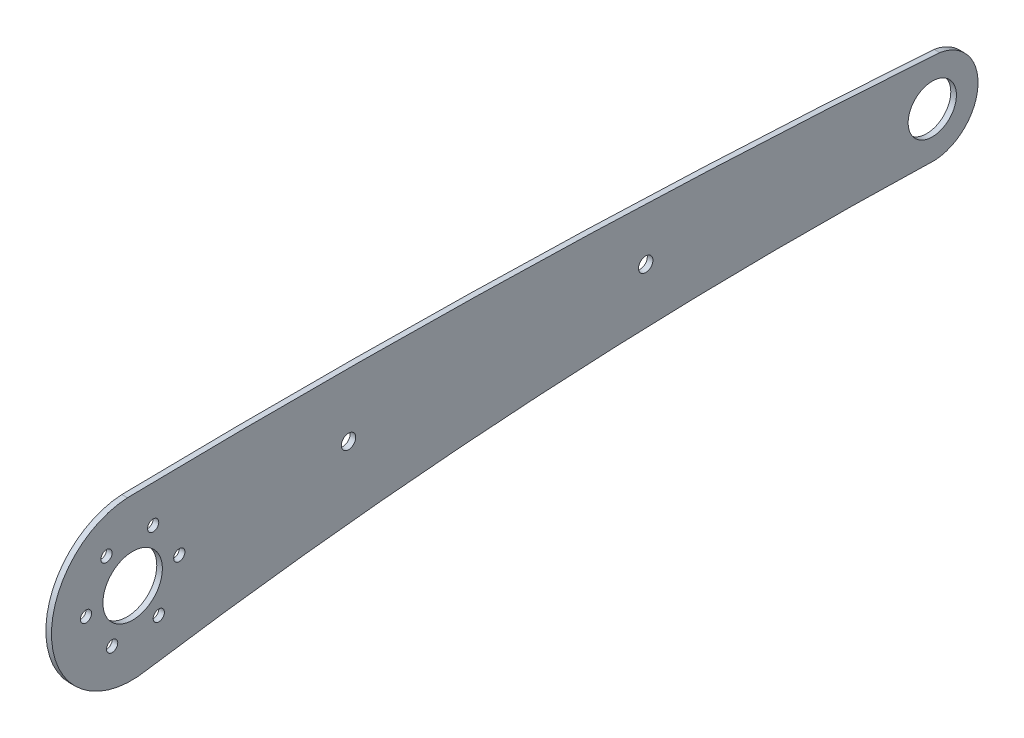
from build123d import *

# Parameters (mm, degrees)
SKETCH_1_R      = 1.5
SKETCH_1_R_2    = 6.45
SKETCH_1_R_3    = 7.95
SKETCH_1_R_4    = 1.925
EXTRUDE_1_DEPTH = 1.5


with BuildPart() as part:
    # 草圖1 → 填料-伸長1 (new body)
    with BuildSketch(Plane(origin=(0, 0, 0), x_dir=(0, 0, -1), z_dir=(1, 0, 0))):
        with BuildLine():
            ThreePointArc((111.555989952, -8.572011863), (6.374730125, -10.137132711), (-98.230068302, -21.244930328))
            ThreePointArc((-98.230068302, -21.244930328), (-123.67575498, -2.873316644), (-103.541794939, 21.20204032))
            ThreePointArc((-103.541794939, 21.20204032), (5.082777822, 20.871677912), (113.584507189, 15.696576829))
            ThreePointArc((113.584507189, 15.696576829), (123.827345593, 3.028727453), (112.406990492, -8.588743688))
            ThreePointArc((112.406990492, -8.588743688), (111.981133536, -8.59851924), (111.555989952, -8.572011863))
        make_face()
        with Locations((-109.133892688, 10.496301174)):
            Circle(SKETCH_1_R, mode=Mode.SUBTRACT)
        with Locations((-114.613532023, -0.738624405)):
            Circle(SKETCH_1_R, mode=Mode.SUBTRACT)
        with Locations((-107.62362073, -11.101594062)):
            Circle(SKETCH_1_R, mode=Mode.SUBTRACT)
        with Locations((-95.154070101, -10.22963814)):
            Circle(SKETCH_1_R, mode=Mode.SUBTRACT)
        with Locations((-89.674430767, 1.005287439)):
            Circle(SKETCH_1_R, mode=Mode.SUBTRACT)
        with Locations((-96.66434206, 11.368257096)):
            Circle(SKETCH_1_R, mode=Mode.SUBTRACT)
        with Locations((111.605339346, 3.621333032)):
            Circle(SKETCH_1_R_2, mode=Mode.SUBTRACT)
        with Locations((-102.143981395, 0.133331517)):
            Circle(SKETCH_1_R_3, mode=Mode.SUBTRACT)
        with Locations((35.001055541, 5.982881827)):
            Circle(SKETCH_1_R_4, mode=Mode.SUBTRACT)
        with Locations((-44.432813653, 4.686665047)):
            Circle(SKETCH_1_R_4, mode=Mode.SUBTRACT)
    extrude(amount=EXTRUDE_1_DEPTH)


solid = part.part
